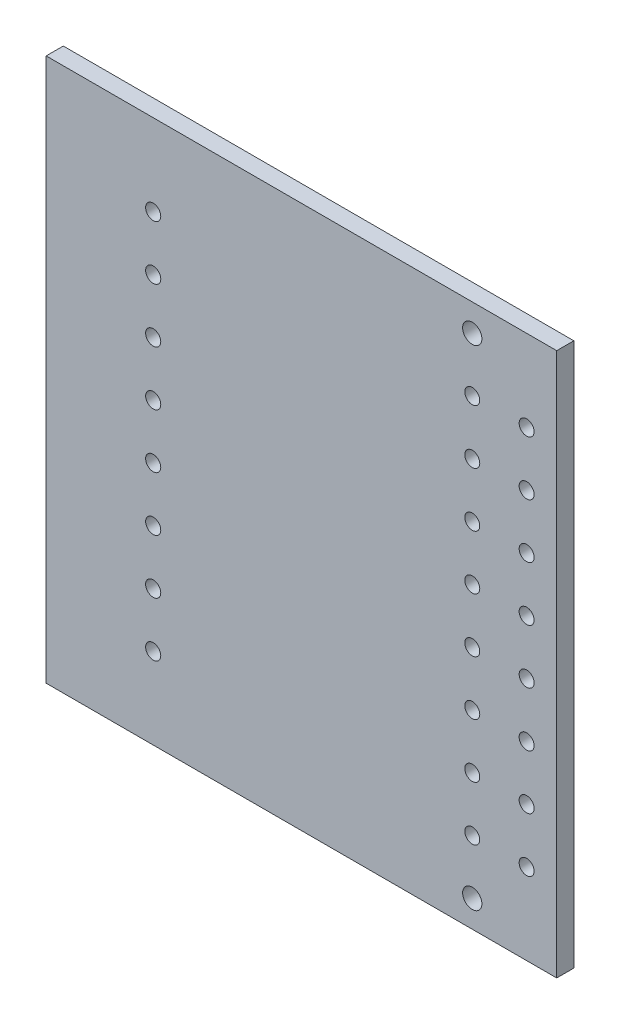
from build123d import *

# Parameters (mm, degrees)
SKETCH1_W           = 47.7000015
SKETCH1_H           = 50.76
SKETCH1_R           = 0.7
SKETCH1_R_2         = 0.707106781
SKETCH1_R_3         = 0.9
BOSS_EXTRUDE1_DEPTH = 1.6


with BuildPart() as part:
    # Sketch1 → Boss-Extrude1 (new body)
    with BuildSketch(Plane.XY):
        with Locations((-123.821418115, -27.467158499)):
            Rectangle(SKETCH1_W, SKETCH1_H)
        with Locations((-107.861418865, -45.267158499)):
            Circle(SKETCH1_R, mode=Mode.SUBTRACT)
        with Locations((-102.781418865, -45.267158499)):
            Circle(SKETCH1_R, mode=Mode.SUBTRACT)
        with Locations((-102.781418865, -40.187158499)):
            Circle(SKETCH1_R, mode=Mode.SUBTRACT)
        with Locations((-102.781418865, -35.107158499)):
            Circle(SKETCH1_R, mode=Mode.SUBTRACT)
        with Locations((-102.781418865, -30.027158499)):
            Circle(SKETCH1_R, mode=Mode.SUBTRACT)
        with Locations((-102.781418865, -24.947158499)):
            Circle(SKETCH1_R, mode=Mode.SUBTRACT)
        with Locations((-102.781418865, -19.867158499)):
            Circle(SKETCH1_R, mode=Mode.SUBTRACT)
        with Locations((-102.781418865, -14.787158499)):
            Circle(SKETCH1_R, mode=Mode.SUBTRACT)
        with Locations((-102.781418865, -9.707158499)):
            Circle(SKETCH1_R, mode=Mode.SUBTRACT)
        with Locations((-107.861418865, -40.187158499)):
            Circle(SKETCH1_R, mode=Mode.SUBTRACT)
        with Locations((-107.861418865, -35.107158499)):
            Circle(SKETCH1_R, mode=Mode.SUBTRACT)
        with Locations((-107.861418865, -30.027158499)):
            Circle(SKETCH1_R, mode=Mode.SUBTRACT)
        with Locations((-107.861418865, -24.947158499)):
            Circle(SKETCH1_R, mode=Mode.SUBTRACT)
        with Locations((-107.861418865, -19.867158499)):
            Circle(SKETCH1_R, mode=Mode.SUBTRACT)
        with Locations((-107.861418865, -14.787158499)):
            Circle(SKETCH1_R, mode=Mode.SUBTRACT)
        with Locations((-107.861418865, -9.707158499)):
            Circle(SKETCH1_R, mode=Mode.SUBTRACT)
        with Locations((-137.671418865, -45.267158499)):
            Circle(SKETCH1_R_2, mode=Mode.SUBTRACT)
        with Locations((-137.671418865, -40.187158499)):
            Circle(SKETCH1_R_2, mode=Mode.SUBTRACT)
        with Locations((-137.671418865, -35.107158499)):
            Circle(SKETCH1_R_2, mode=Mode.SUBTRACT)
        with Locations((-137.671418865, -30.027158499)):
            Circle(SKETCH1_R_2, mode=Mode.SUBTRACT)
        with Locations((-137.671418865, -24.947158499)):
            Circle(SKETCH1_R_2, mode=Mode.SUBTRACT)
        with Locations((-137.671418865, -19.867158499)):
            Circle(SKETCH1_R_2, mode=Mode.SUBTRACT)
        with Locations((-137.671418865, -14.787158499)):
            Circle(SKETCH1_R_2, mode=Mode.SUBTRACT)
        with Locations((-137.671418865, -9.707158499)):
            Circle(SKETCH1_R_2, mode=Mode.SUBTRACT)
        with Locations((-107.861418865, -50.347158499)):
            Circle(SKETCH1_R_3, mode=Mode.SUBTRACT)
        with Locations((-107.861418865, -4.627158499)):
            Circle(SKETCH1_R_3, mode=Mode.SUBTRACT)
    extrude(amount=BOSS_EXTRUDE1_DEPTH)


solid = part.part
